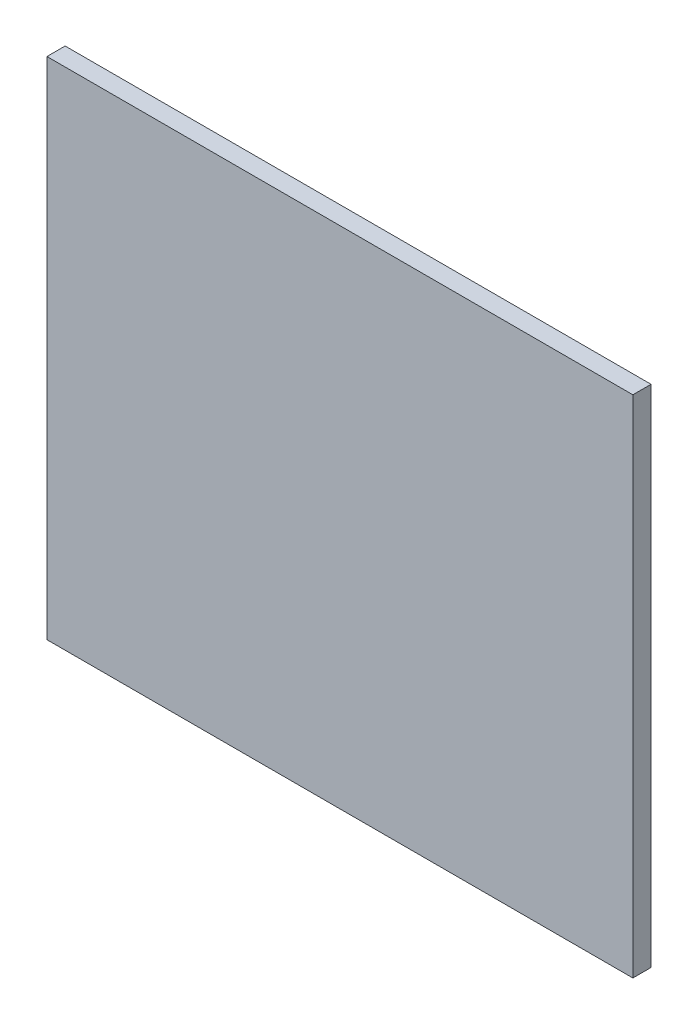
from build123d import *

# Parameters (mm, degrees)
SKETCH1_W           = 290
SKETCH1_H           = 250
BOSS_EXTRUDE1_DEPTH = 9


with BuildPart() as part:
    # Sketch1 → Boss-Extrude1 (new body)
    with BuildSketch(Plane.XY):
        with Locations((145, 125)):
            Rectangle(SKETCH1_W, SKETCH1_H)
    extrude(amount=BOSS_EXTRUDE1_DEPTH)


solid = part.part
